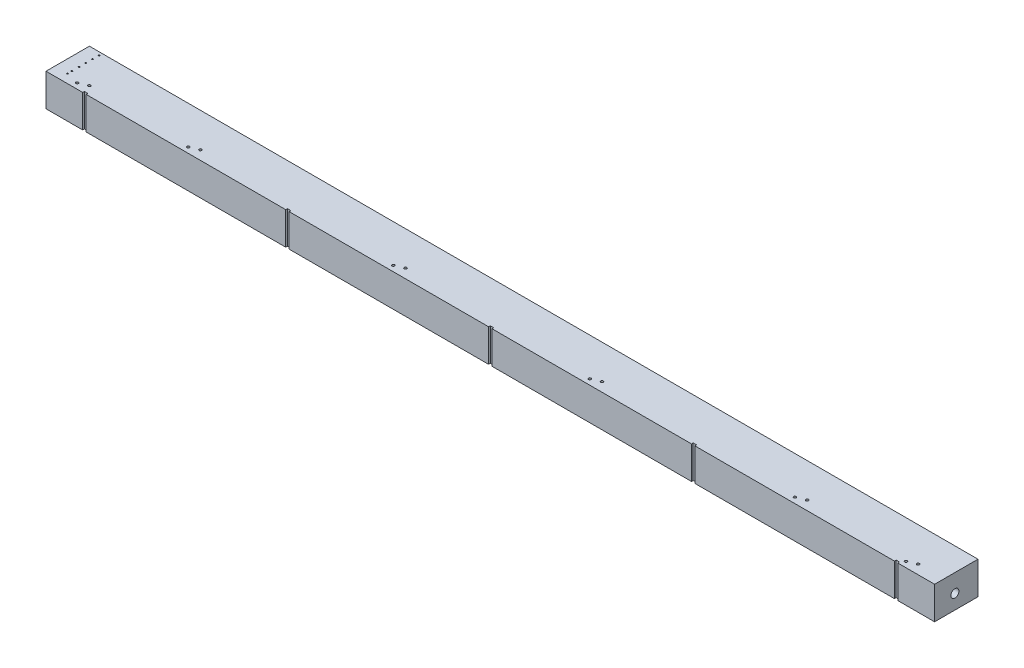
from build123d import *

# Parameters (mm, degrees)
SKETCH1_W           = 1040
SKETCH1_H           = 50.8
BOSS_EXTRUDE1_DEPTH = 38.1
SKETCH7_R           = 1.5
CUT_EXTRUDE14_DEPTH = 5
CUT_EXTRUDE15_DEPTH = 10
CUT_EXTRUDE16_DEPTH = 4.7625
SKETCH2_W           = 4
SKETCH2_H           = 2
CUT_EXTRUDE18_DEPTH = 39.1
HOLE2_AT_2_COUNT    = 2
HOLE2_AT_2_PITCH    = 7.831
HOLE2_AT_3_COUNT    = 2
HOLE2_AT_3_PITCH    = 15.681
HOLE2_AT_4_COUNT    = 2
HOLE2_AT_4_PITCH    = 23.512
HOLE2_AT_5_COUNT    = 2
HOLE2_AT_5_PITCH    = 32.02
HOLE2_AT_6_COUNT    = 2
HOLE2_AT_6_PITCH    = 37.132
CUT_EXTRUDE19_DEPTH = 11


with BuildPart() as part:
    # Sketch1 → Boss-Extrude1 (new body)
    with BuildSketch(Plane(origin=(0, 0, 0), x_dir=(1, 0, 0), z_dir=(0, 1, 0))):
        with Locations((520, 25.4)):
            Rectangle(SKETCH1_W, SKETCH1_H)
    extrude(amount=BOSS_EXTRUDE1_DEPTH)

    # Sketch7 → Cut-Extrude14 (cut)
    with BuildSketch(Plane(origin=(0, 38.1, 0), x_dir=(1, 0, 0), z_dir=(0, 1, 0))):
        with Locations(Location((400, 6.513, 0), (0, 0, 270))):  # turned: the seam where the file's is
            Circle(SKETCH7_R)
        with Locations(Location((160, 6.513, 0), (0, 0, 270))):  # turned: the seam where the file's is
            Circle(SKETCH7_R)
        with Locations(Location((870, 6.513, 0), (0, 0, 270))):  # turned: the seam where the file's is
            Circle(SKETCH7_R)
        with Locations(Location((630, 6.513, 0), (0, 0, 270))):  # turned: the seam where the file's is
            Circle(SKETCH7_R)
        with Locations(Location((170, 10.725, 0), (0, 0, 270))):  # turned: the seam where the file's is
            Circle(SKETCH7_R)
        with Locations(Location((30, 6.513, 0), (0, 0, 270))):  # turned: the seam where the file's is
            Circle(SKETCH7_R)
        with Locations(Location((40, 10.725, 0), (0, 0, 270))):  # turned: the seam where the file's is
            Circle(SKETCH7_R)
        with Locations(Location((1000, 6.513, 0), (0, 0, 270))):  # turned: the seam where the file's is
            Circle(SKETCH7_R)
        with Locations(Location((410, 10.725, 0), (0, 0, 270))):  # turned: the seam where the file's is
            Circle(SKETCH7_R)
        with Locations(Location((1010, 10.725, 0), (0, 0, 270))):  # turned: the seam where the file's is
            Circle(SKETCH7_R)
        with Locations(Location((640, 10.725, 0), (0, 0, 270))):  # turned: the seam where the file's is
            Circle(SKETCH7_R)
        with Locations(Location((880, 10.725, 0), (0, 0, 270))):  # turned: the seam where the file's is
            Circle(SKETCH7_R)
    extrude(amount=-CUT_EXTRUDE14_DEPTH, mode=Mode.SUBTRACT)

    # Sketch8 → Cut-Extrude15 (cut)
    with BuildSketch(Plane.XZ):
        with BuildLine():
            Line((12, -44.8), (1028, -44.8))
            ThreePointArc((1028, -44.8), (1032.242640687, -43.042640687), (1034, -38.8))
            Line((1034, -38.8), (1034, -12))
            ThreePointArc((1034, -12), (1032.242640687, -7.757359313), (1028, -6))
            Line((1028, -6), (12, -6))
            ThreePointArc((12, -6), (7.757359313, -7.757359313), (6, -12))
            Line((6, -12), (6, -38.8))
            ThreePointArc((6, -38.8), (7.757359313, -43.042640687), (12, -44.8))
        make_face()
    extrude(amount=-CUT_EXTRUDE15_DEPTH, mode=Mode.SUBTRACT)

    # Sketch8_3 → Cut-Extrude16 (cut)
    with BuildSketch(Plane.XZ):
        with BuildLine():
            Line((9, -47.8), (1031, -47.8))
            ThreePointArc((1031, -47.8), (1035.242640687, -46.042640687), (1037, -41.8))
            Line((1037, -41.8), (1037, -9))
            ThreePointArc((1037, -9), (1035.242640687, -4.757359313), (1031, -3))
            Line((1031, -3), (9, -3))
            ThreePointArc((9, -3), (4.757359313, -4.757359313), (3, -9))
            Line((3, -9), (3, -41.8))
            ThreePointArc((3, -41.8), (4.757359313, -46.042640687), (9, -47.8))
        make_face()
    extrude(amount=-CUT_EXTRUDE16_DEPTH, mode=Mode.SUBTRACT)

    # Sketch2 → Cut-Extrude18 (cut, through all)
    with BuildSketch(Plane(origin=(0, 38.1, 0), x_dir=(1, 0, 0), z_dir=(0, 1, 0))):
        with Locations((45, 1)):
            Rectangle(SKETCH2_W, SKETCH2_H)
        with Locations((282.5, 1)):
            Rectangle(SKETCH2_W, SKETCH2_H)
        with Locations((520, 1)):
            Rectangle(SKETCH2_W, SKETCH2_H)
        with Locations((757.5, 1)):
            Rectangle(SKETCH2_W, SKETCH2_H)
        with Locations((995, 1)):
            Rectangle(SKETCH2_W, SKETCH2_H)
    extrude(amount=-CUT_EXTRUDE18_DEPTH, mode=Mode.SUBTRACT)

    # Sketch12 → 1_8 NPT Tapped Hole2 (revolve, cut)
    with BuildSketch(Plane(origin=(1040, 17, -23.733), x_dir=(0, 0, -1), z_dir=(0, 1, 0))):
        Polygon((0, 0), (0, 27.533468714), (4.2164, 25), (4.2164, 6.92), (4.537398933, 6.92), (4.744593, 0), align=None)
    revolve(axis=Axis((1046.35, 17, -23.733), (-1, 0, 0)), mode=Mode.SUBTRACT)

    # Sketch14 → 1_8 NPT Tapped Hole3 (revolve, cut)
    with BuildSketch(Plane(origin=(0, 17, -23.733), x_dir=(0, 0, 1), z_dir=(0, 1, 0))):
        Polygon((0, 0), (0, 27.533468714), (4.2164, 25), (4.2164, 6.92), (4.537398933, 6.92), (4.744593, 0), align=None)
    revolve(axis=Axis((-6.35, 17, -23.733), (1, 0, 0)), mode=Mode.SUBTRACT)

    # Sketch26 → Hole2 (revolve, cut)
    with BuildSketch(Plane(origin=(15, 10, -47.245), x_dir=(0, 0, -1), z_dir=(1, 0, 0))):
        Polygon((0, 0), (0, 28.1), (0.79375, 28.1), (0.79375, 20.953866233), (2.38125, 20), (2.38125, 0), align=None)
    hole2 = revolve(axis=Axis((15, 3.869976101, -47.245), (0, 1, 0)), mode=Mode.SUBTRACT)

    # Hole2 at 2: Hole2 ×2
    with Locations(*[(0, 0, i * HOLE2_AT_2_PITCH) for i in range(1, HOLE2_AT_2_COUNT)]):
        add(hole2, mode=Mode.SUBTRACT)

    # Hole2 at 3: Hole2 ×2
    with Locations(*[(0, 0, i * HOLE2_AT_3_PITCH) for i in range(1, HOLE2_AT_3_COUNT)]):
        add(hole2, mode=Mode.SUBTRACT)

    # Hole2 at 4: Hole2 ×2
    with Locations(*[(0, 0, i * HOLE2_AT_4_PITCH) for i in range(1, HOLE2_AT_4_COUNT)]):
        add(hole2, mode=Mode.SUBTRACT)

    # Hole2 at 5: Hole2 ×2
    with Locations(*[(0, 0, i * HOLE2_AT_5_PITCH) for i in range(1, HOLE2_AT_5_COUNT)]):
        add(hole2, mode=Mode.SUBTRACT)

    # Hole2 at 6: Hole2 ×2
    with Locations(*[(0, 0, i * HOLE2_AT_6_PITCH) for i in range(1, HOLE2_AT_6_COUNT)]):
        add(hole2, mode=Mode.SUBTRACT)

    # Sketch29 → Cut-Extrude19 (cut)
    with BuildSketch(Plane.XZ.offset(-10)):
        with BuildLine():
            Line((12.175, -19.5165), (23.825, -19.5165))
            ThreePointArc((23.825, -19.5165), (28.0415, -23.733), (23.825, -27.9495))
            Line((23.825, -27.9495), (12.175, -27.9495))
            ThreePointArc((12.175, -27.9495), (7.9585, -23.733), (12.175, -19.5165))
        make_face()
        with BuildLine():
            Line((1016.175, -19.5165), (1027.825, -19.5165))
            ThreePointArc((1027.825, -19.5165), (1032.0415, -23.733), (1027.825, -27.9495))
            Line((1027.825, -27.9495), (1016.175, -27.9495))
            ThreePointArc((1016.175, -27.9495), (1011.9585, -23.733), (1016.175, -19.5165))
        make_face()
    extrude(amount=-CUT_EXTRUDE19_DEPTH, mode=Mode.SUBTRACT)


solid = part.part
